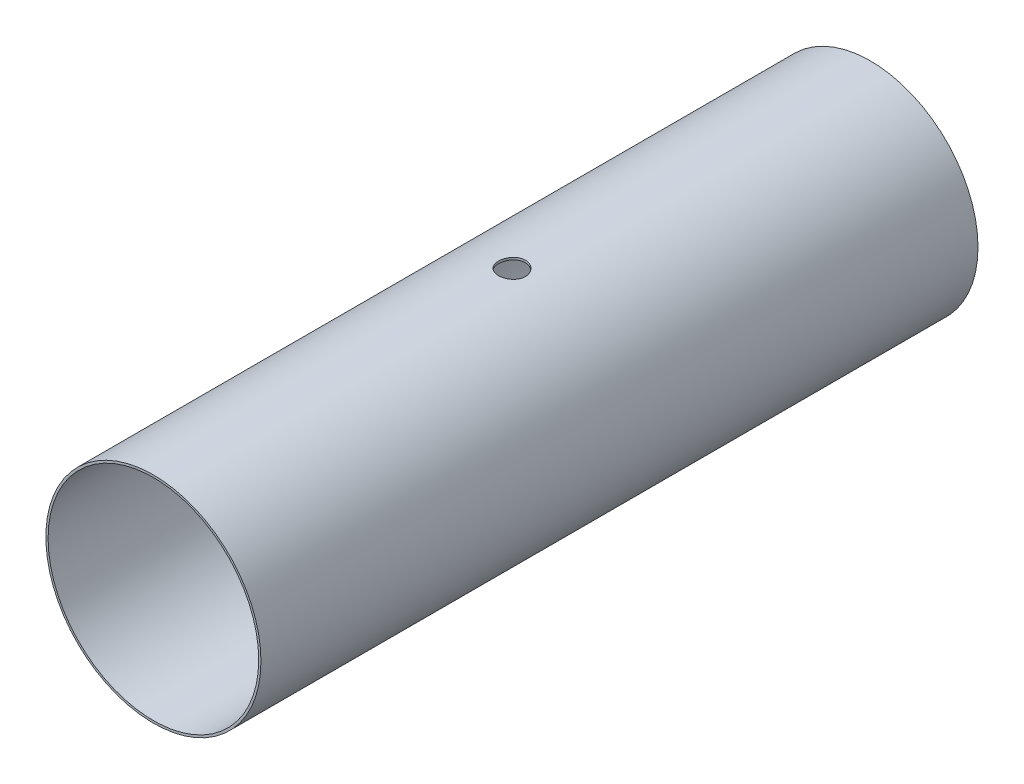
from build123d import *

# Parameters (mm, degrees)
SKETCH1_R               = 152.4
BOSS_EXTRUDE1_DEPTH     = 1016
SKETCH2_R               = 149.225
CUT_EXTRUDE1_DEPTH      = 1016
SKETCH4_R               = 19.05
CUT_EXTRUDE3_DEPTH      = 441.96
CUT_EXTRUDE3_DEPTH_BACK = 459.754024061


with BuildPart() as part:
    # Sketch1 → Boss-Extrude1 (new body)
    with BuildSketch(Plane.XY):
        Circle(SKETCH1_R)
    extrude(amount=BOSS_EXTRUDE1_DEPTH)

    # Sketch2 → Cut-Extrude1 (cut)
    with BuildSketch(Plane.XY.offset(1016)):
        Circle(SKETCH2_R)
    extrude(amount=-CUT_EXTRUDE1_DEPTH, mode=Mode.SUBTRACT)

    # Sketch4 → Cut-Extrude3 (cut, two sides)
    with BuildSketch(Plane(origin=(0, 0, 0), x_dir=(1, 0, 0), z_dir=(0, 1, 0))) as cut_extrude3_sk:
        with Locations((0, -508)):
            Circle(SKETCH4_R)
    extrude(amount=CUT_EXTRUDE3_DEPTH, mode=Mode.SUBTRACT)
    extrude(cut_extrude3_sk.sketch, amount=-CUT_EXTRUDE3_DEPTH_BACK, mode=Mode.SUBTRACT)


solid = part.part
